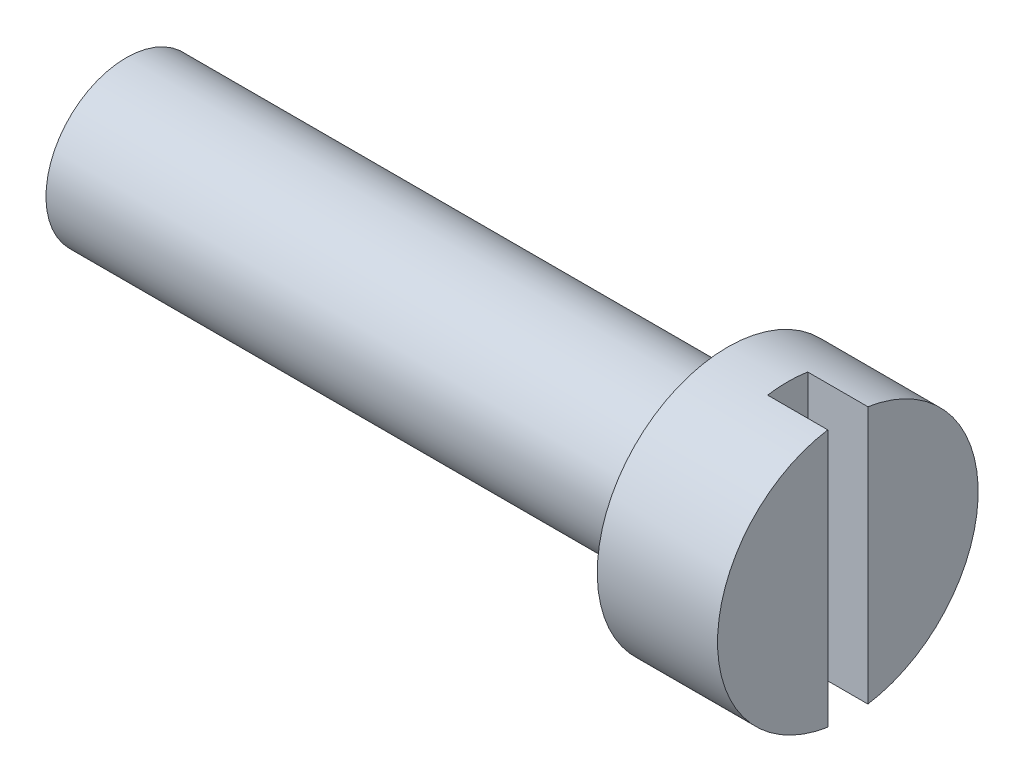
from build123d import *

# Parameters (mm, degrees)
SKETCH2_W          = 1
SKETCH2_H          = 6.5
CUT_EXTRUDE1_DEPTH = 1.5


with BuildPart() as part:
    # Sketch1 → Revolve1 (revolve)
    with BuildSketch(Plane.XY):
        Polygon((0, 0), (-18, 0), (-18, 2), (-3, 2), (-3, 3.25), (0, 3.25), align=None)
    revolve(axis=Axis((0, 0, 0), (-1, 0, 0)))

    # Sketch2 → Cut-Extrude1 (cut)
    with BuildSketch(Plane(origin=(0, 0, 0), x_dir=(0, 0, -1), z_dir=(1, 0, 0))):
        Rectangle(SKETCH2_W, SKETCH2_H)
    extrude(amount=-CUT_EXTRUDE1_DEPTH, mode=Mode.SUBTRACT)


solid = part.part
